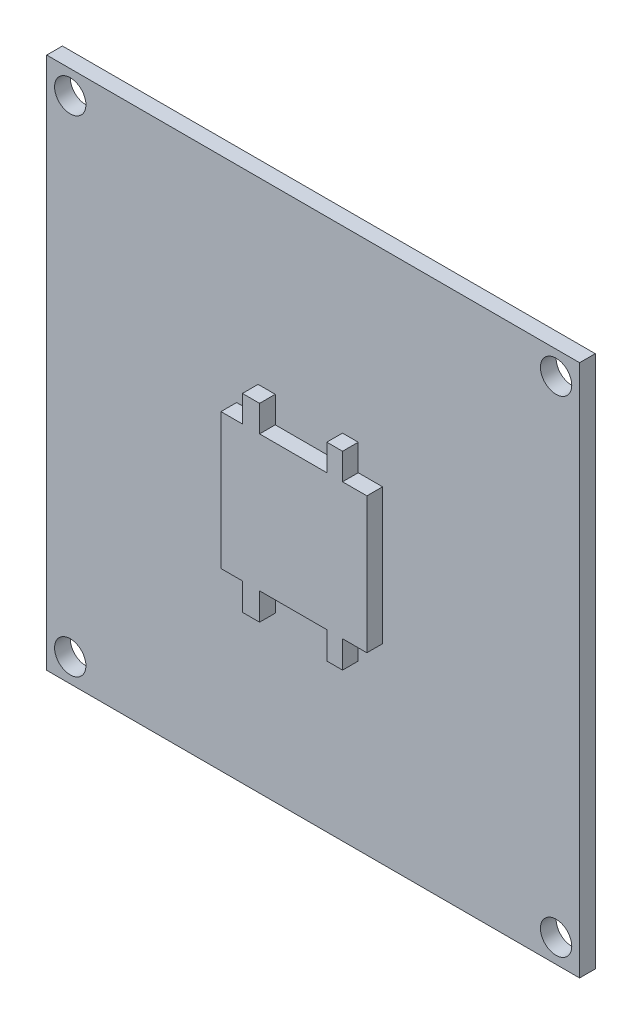
from build123d import *

# Parameters (mm, degrees)
CROQUIS1_W              = 34
CROQUIS1_H              = 34
CROQUIS1_R              = 1
SALIENTE_EXTRUIR1_DEPTH = 1
CROQUIS2_W              = 9.310717014
CROQUIS2_H              = 8.671746239
CROQUIS2_W_2            = 1.095378472
CROQUIS2_H_2            = 1.688708478
CROQUIS2_W_3            = 1.004096933
CROQUIS2_H_3            = 1.734349248
SALIENTE_EXTRUIR2_DEPTH = 1


with BuildPart() as part:
    # Croquis1 → Saliente-Extruir1 (new body)
    with BuildSketch(Plane.XY):
        with Locations((17, 17)):
            Rectangle(CROQUIS1_W, CROQUIS1_H)
        with Locations((1.5, 32.5)):
            Circle(CROQUIS1_R, mode=Mode.SUBTRACT)
        with Locations((32.5, 32.5)):
            Circle(CROQUIS1_R, mode=Mode.SUBTRACT)
        with Locations((1.5, 1.5)):
            Circle(CROQUIS1_R, mode=Mode.SUBTRACT)
        with Locations((32.5, 1.5)):
            Circle(CROQUIS1_R, mode=Mode.SUBTRACT)
    extrude(amount=SALIENTE_EXTRUIR1_DEPTH)

    # Croquis2 → Saliente-Extruir2 (add)
    with BuildSketch(Plane.XY.offset(1)):
        with Locations((16.771796152, 16.520771918)):
            Rectangle(CROQUIS2_W, CROQUIS2_H)
        with Locations((14.033349971, 21.700999277)):
            Rectangle(CROQUIS2_W_2, CROQUIS2_H_2)
        with Locations((19.373320023, 21.700999277)):
            Rectangle(CROQUIS2_W_3, CROQUIS2_H_2)
        with Locations((14.033349971, 11.317724175)):
            Rectangle(CROQUIS2_W_2, CROQUIS2_H_3)
        with Locations((19.373320023, 11.317724175)):
            Rectangle(CROQUIS2_W_3, CROQUIS2_H_3)
    extrude(amount=SALIENTE_EXTRUIR2_DEPTH)


solid = part.part
